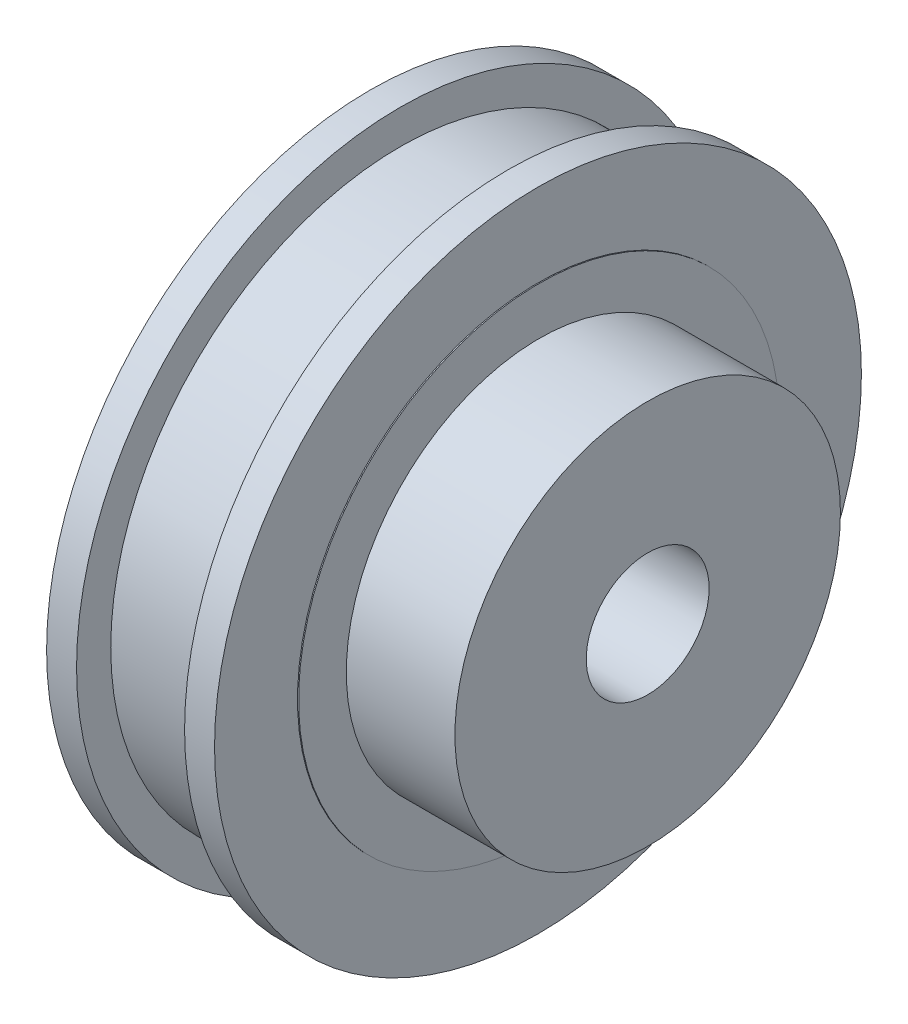
from build123d import *

# Parameters (mm, degrees)
SKETCH1_R           = 21.05
BOSS_EXTRUDE1_DEPTH = 10.93
SKETCH2_R           = 15.65
BOSS_EXTRUDE2_DEPTH = 0.07
SKETCH3_W           = 7.03
SKETCH3_H           = 2.225
SKETCH5_R           = 12.545
BOSS_EXTRUDE3_DEPTH = 7.14
SKETCH6_R           = 4
CUT_EXTRUDE1_DEPTH  = 19.14


with BuildPart() as part:
    # Sketch1 → Boss-Extrude1 (new body)
    with BuildSketch(Plane(origin=(0, 0, 0), x_dir=(0, 0, -1), z_dir=(1, 0, 0))):
        Circle(SKETCH1_R)
    extrude(amount=BOSS_EXTRUDE1_DEPTH)

    # Sketch2 → Boss-Extrude2 (add)
    with BuildSketch(Plane(origin=(10.93, 0, 0), x_dir=(0, 0, -1), z_dir=(1, 0, 0))):
        Circle(SKETCH2_R)
    extrude(amount=BOSS_EXTRUDE2_DEPTH)

    # Mirror1: part across plane


with BuildPart() as part_1:
    add(part.part)
    add(part.part.mirror(Plane(origin=(5.465, 0, 0), x_dir=(0, 0, 1), z_dir=(1, 0, 0))))

    # Sketch3 → Cut-Revolve1 (revolve, cut)
    with BuildSketch(Plane.XY):
        with Locations((5.465, 19.9375)):
            Rectangle(SKETCH3_W, SKETCH3_H)
    revolve(axis=Axis((0, 0, 0), (1, 0, 0)), mode=Mode.SUBTRACT)

    # Sketch5 → Boss-Extrude3 (add)
    with BuildSketch(Plane(origin=(10.93, 0, 0), x_dir=(0, 0, -1), z_dir=(1, 0, 0))):
        Circle(SKETCH5_R)
    extrude(amount=BOSS_EXTRUDE3_DEPTH)

    # Sketch6 → Cut-Extrude1 (cut, through all)
    with BuildSketch(Plane(origin=(18.07, 0, 0), x_dir=(0, 0, -1), z_dir=(1, 0, 0))):
        Circle(SKETCH6_R)
    extrude(amount=-CUT_EXTRUDE1_DEPTH, mode=Mode.SUBTRACT)


solid = part_1.part
